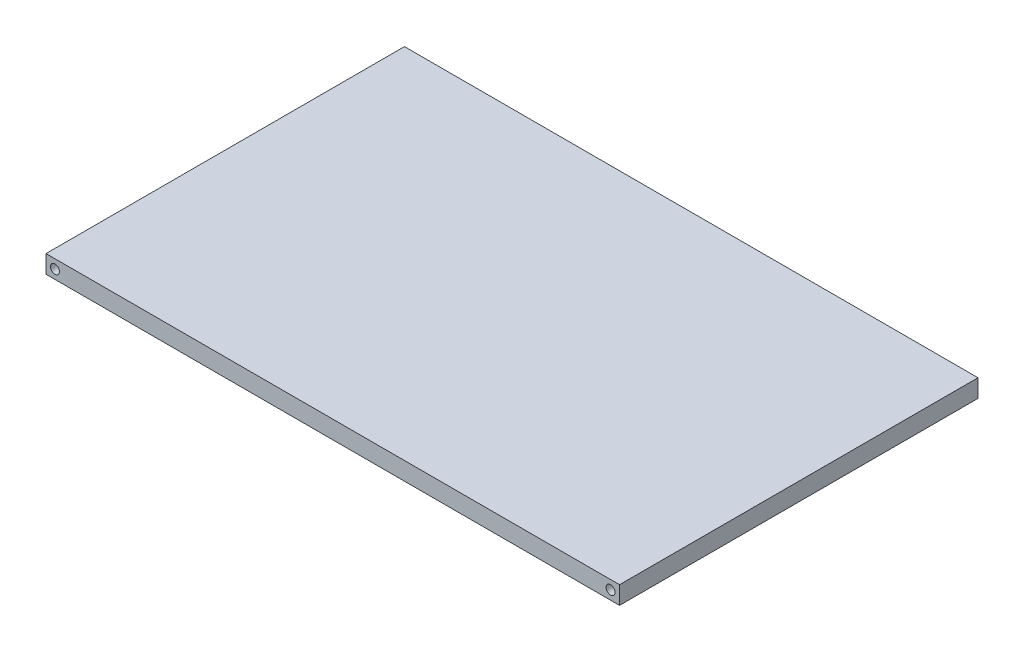
from build123d import *

# Parameters (mm, degrees)
SKETCH1_W           = 101.6
SKETCH1_H           = 63.5
BOSS_EXTRUDE1_DEPTH = 3.175
SKETCH2_R           = 0.79375
CUT_EXTRUDE1_DEPTH  = 6.35
SKETCH3_R           = 0.79375
CUT_EXTRUDE2_DEPTH  = 6.35


with BuildPart() as part:
    # Sketch1 → Boss-Extrude1 (new body)
    with BuildSketch(Plane(origin=(0, 0, 0), x_dir=(1, 0, 0), z_dir=(0, 1, 0))):
        with Locations((8.595554542, -11.095875723)):
            Rectangle(SKETCH1_W, SKETCH1_H)
    extrude(amount=BOSS_EXTRUDE1_DEPTH)

    # Sketch2 → Cut-Extrude1 (cut)
    with BuildSketch(Plane.XY.offset(42.845875723)):
        with Locations((-40.616945458, 1.5875)):
            Circle(SKETCH2_R)
        with Locations((57.808054542, 1.5875)):
            Circle(SKETCH2_R)
    extrude(amount=-CUT_EXTRUDE1_DEPTH, mode=Mode.SUBTRACT)

    # Sketch3 → Cut-Extrude2 (cut)
    with BuildSketch(Plane(origin=(0, 0, -20.654124277), x_dir=(-1, 0, 0), z_dir=(0, 0, -1))):
        with Locations(Location((-57.808054542, 1.5875, 0), (0, 0, 180))):  # turned: the seam where the file's is
            Circle(SKETCH3_R)
        with Locations(Location((40.616945458, 1.5875, 0), (0, 0, 180))):  # turned: the seam where the file's is
            Circle(SKETCH3_R)
    extrude(amount=-CUT_EXTRUDE2_DEPTH, mode=Mode.SUBTRACT)


solid = part.part
